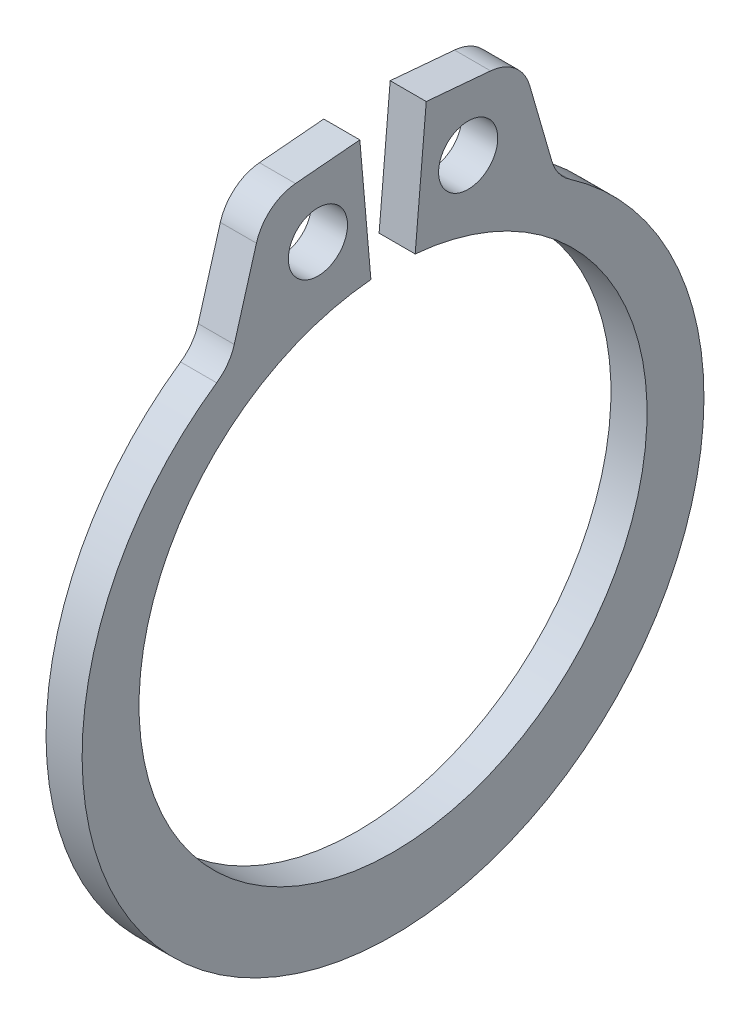
from build123d import *

# Parameters (mm, degrees)
SKETCH1_R      = 0.5207
EXTRUDE1_DEPTH = 0.3175
FILLET1_R      = 0.7874


with BuildPart() as part:
    # Sketch1 → Extrude1 (new body, symmetric)
    with BuildSketch(Plane(origin=(0, 0, 0), x_dir=(0, 0, -1), z_dir=(1, 0, 0))):
        with BuildLine():
            Line((-0.389621032, 4.453388778), (-0.584431549, 6.680083168))
            Line((-0.584431549, 6.680083168), (-2.25445234, 6.53397528))
            Line((-2.25445234, 6.53397528), (-2.87534029, 4.386740502))
            ThreePointArc((-2.87534029, 4.386740502), (0, -5.7404), (2.87534029, 4.386740502))
            Line((2.87534029, 4.386740502), (2.25445234, 6.53397528))
            Line((2.25445234, 6.53397528), (0.584431549, 6.680083168))
            Line((0.584431549, 6.680083168), (0.389621032, 4.453388778))
            ThreePointArc((0.389621032, 4.453388778), (0, -4.4704), (-0.389621032, 4.453388778))
        make_face()
        with Locations((-1.322036686, 5.493682029)):
            Circle(SKETCH1_R, mode=Mode.SUBTRACT)
        with Locations((1.322036686, 5.493682029)):
            Circle(SKETCH1_R, mode=Mode.SUBTRACT)
    extrude(amount=EXTRUDE1_DEPTH, both=True)

    # Fillet1
    fillet1_edges = [part.edges().sort_by_distance(p)[0] for p in [
        (0, 6.53397528, -2.25445234),
        (0, 4.386740502, -2.87534029),
        (0, 4.386740502, 2.87534029),
        (0, 6.53397528, 2.25445234),
    ]]
    fillet(fillet1_edges, radius=FILLET1_R)


solid = part.part
